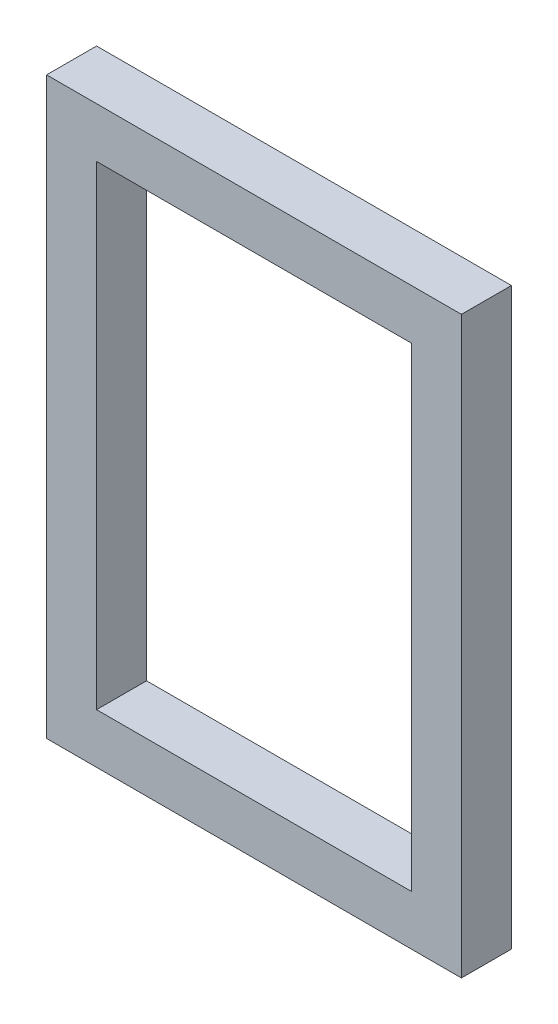
from build123d import *

# Parameters (mm, degrees)
SKETCH1_W           = 21.082
SKETCH1_H           = 29.21
BOSS_EXTRUDE1_DEPTH = 2.54
SKETCH2_W           = 16.002
SKETCH2_H           = 24.13
CUT_EXTRUDE1_DEPTH  = 3.54


with BuildPart() as part:
    # Sketch1 → Boss-Extrude1 (new body)
    with BuildSketch(Plane.XY):
        Rectangle(SKETCH1_W, SKETCH1_H)
    extrude(amount=BOSS_EXTRUDE1_DEPTH)

    # Sketch2 → Cut-Extrude1 (cut, through all)
    with BuildSketch(Plane.XY.offset(2.54)):
        Rectangle(SKETCH2_W, SKETCH2_H)
    extrude(amount=-CUT_EXTRUDE1_DEPTH, mode=Mode.SUBTRACT)


solid = part.part
